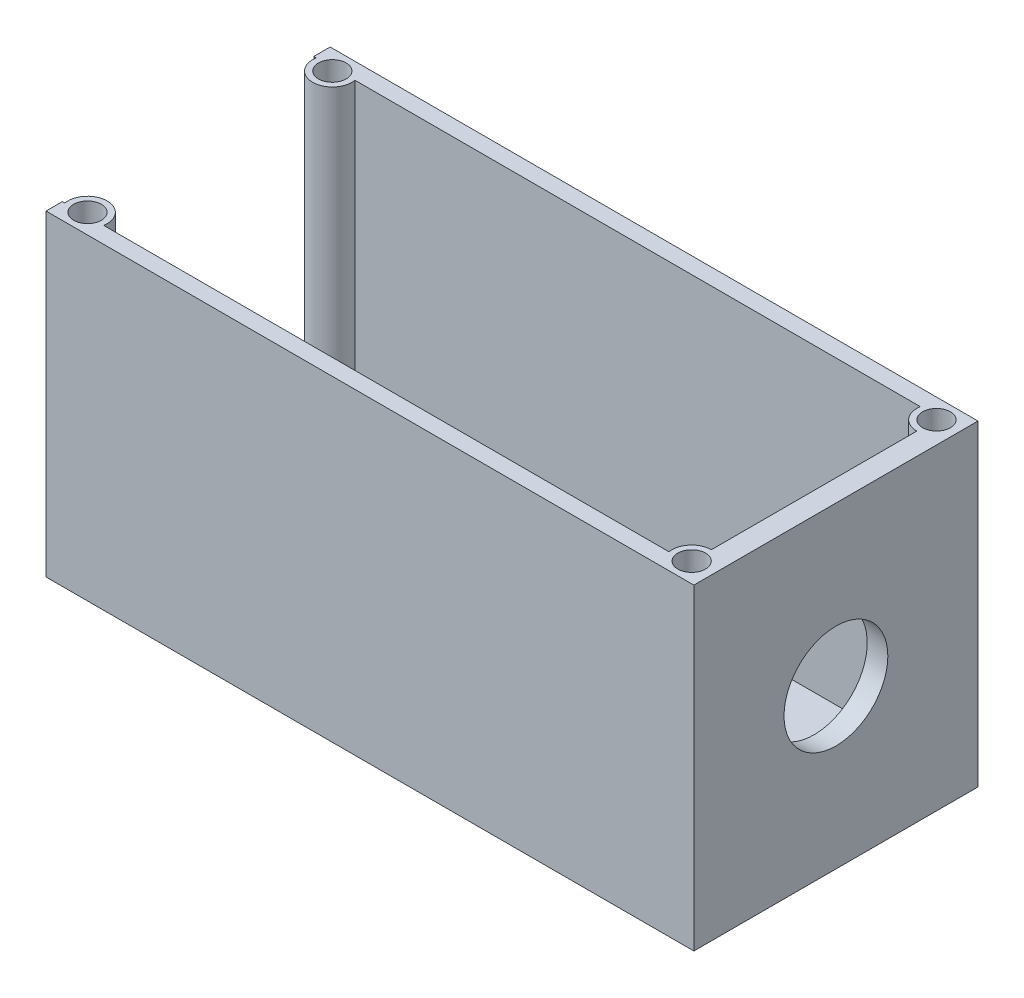
from build123d import *

# Parameters (mm, degrees)
SKETCH1_W                 = 59.28
SKETCH1_H                 = 26
BOSS_EXTRUDE2_DEPTH       = 29
SKETCH3_W                 = 57.28
SKETCH3_H                 = 23
CUT_EXTRUDE1_DEPTH        = 27.5
SKETCH4_R                 = 4.75
SKETCH5_R                 = 4.8654
SKETCH9_R                 = 1.8
BOSS_EXTRUDE4_DEPTH       = 27.5
F_2_0MM_DOWEL_HOLE3_D     = 2.54
F_2_0MM_DOWEL_HOLE3_DEPTH = 10
MIRROR2_COPY_1_SKETCH_R   = 1.8
MIRROR2_COPY_1_DEPTH      = 27.5
MIRROR2_COPY_2_D          = 2.54
MIRROR2_COPY_2_DEPTH      = 10


with BuildPart() as part:
    # Sketch1 → Boss-Extrude2 (new body)
    with BuildSketch(Plane(origin=(0, 0, 0), x_dir=(1, 0, 0), z_dir=(0, 1, 0))):
        with Locations((29.64, 13)):
            Rectangle(SKETCH1_W, SKETCH1_H)
    extrude(amount=BOSS_EXTRUDE2_DEPTH)

    # Sketch3 → Cut-Extrude1 (cut)
    with BuildSketch(Plane(origin=(0, 29, 0), x_dir=(1, 0, 0), z_dir=(0, 1, 0))):
        with Locations((28.64, 13)):
            Rectangle(SKETCH3_W, SKETCH3_H)
    extrude(amount=-CUT_EXTRUDE1_DEPTH, mode=Mode.SUBTRACT)

    # Sketch4 → Cut-Loft1 section 0
    with BuildSketch(Plane(origin=(59.28, 0, 0), x_dir=(0, 0, -1), z_dir=(1, 0, 0))):
        with Locations((13, 14.5)):
            Circle(SKETCH4_R)
    # Sketch5 → Cut-Loft1 section 1
    with BuildSketch(Plane.ZY.offset(-57.28)):
        with Locations((-13, 14.5)):
            Circle(SKETCH5_R)
    loft(mode=Mode.SUBTRACT)

    # Sketch9 → Boss-Extrude4 (add)
    with BuildSketch(Plane(origin=(0, 29, 0), x_dir=(1, 0, 0), z_dir=(0, 1, 0))):
        with Locations((57.28, 1.8)):
            Circle(SKETCH9_R)
    boss_extrude4 = extrude(amount=-BOSS_EXTRUDE4_DEPTH)

    # Ø2.0mm Dowel Hole3
    with Locations(Plane(origin=(0, 29, 0), x_dir=(1, 0, 0), z_dir=(0, 1, 0))):
        with Locations((57.28, 1.8)):
            f_2_0mm_dowel_hole3 = Hole(F_2_0MM_DOWEL_HOLE3_D / 2, depth=F_2_0MM_DOWEL_HOLE3_DEPTH)

    # Mirror1: Boss-Extrude4, Ø2.0mm Dowel Hole3 across plane
    add(boss_extrude4.mirror(Plane(origin=(0, 0, -13), x_dir=(1, 0, 0), z_dir=(0, 0, -1))))
    add(f_2_0mm_dowel_hole3.mirror(Plane(origin=(0, 0, -13), x_dir=(1, 0, 0), z_dir=(0, 0, -1))), mode=Mode.SUBTRACT)

    # Mirror2: Boss-Extrude4, Ø2.0mm Dowel Hole3 across plane
    add(boss_extrude4.mirror(Plane.ZY.offset(-29.64)))
    add(f_2_0mm_dowel_hole3.mirror(Plane.ZY.offset(-29.64)), mode=Mode.SUBTRACT)

    # Mirror2 copy 1 sketch → Mirror2 copy 1 (add)
    with BuildSketch(Plane(origin=(59.28, 29, -26), x_dir=(-1, 0, 0), z_dir=(0, 1, 0))):
        with Locations((57.28, 1.8)):
            Circle(MIRROR2_COPY_1_SKETCH_R)
    extrude(amount=-MIRROR2_COPY_1_DEPTH)

    # Mirror2 copy 2
    with Locations(Plane(origin=(59.28, 29, -26), x_dir=(-1, 0, 0), z_dir=(0, 1, 0))):
        with Locations((57.28, 1.8)):
            Hole(MIRROR2_COPY_2_D / 2, depth=MIRROR2_COPY_2_DEPTH)


solid = part.part
